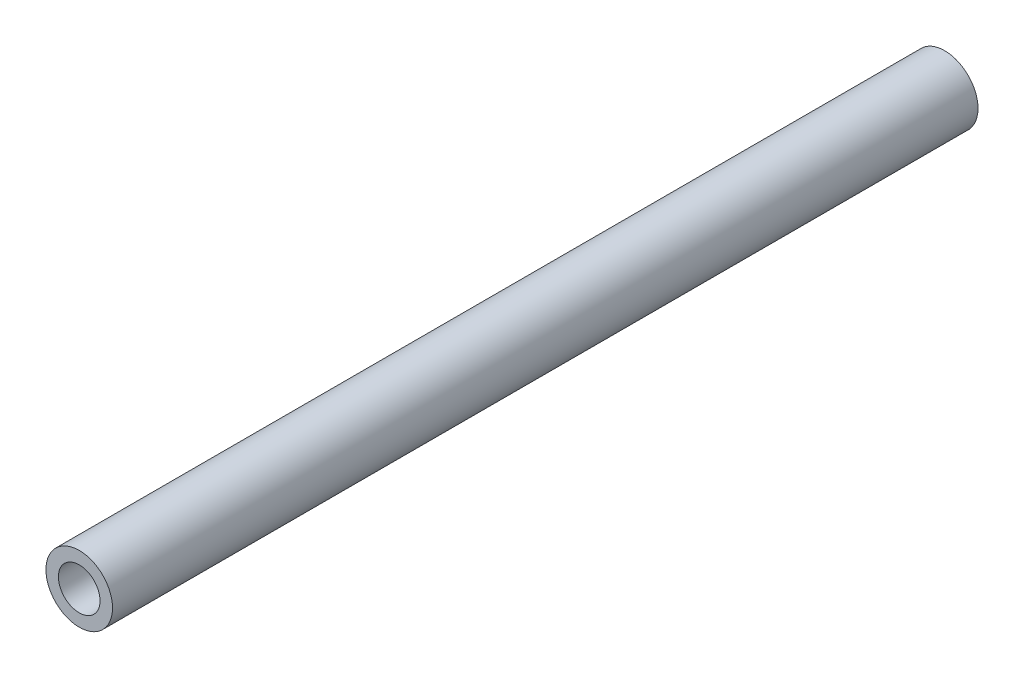
from build123d import *

# Parameters (mm, degrees)
SKETCH1_R           = 4
SKETCH1_R_2         = 2.5
BOSS_EXTRUDE1_DEPTH = 104


with BuildPart() as part:
    # Sketch1 → Boss-Extrude1 (new body)
    with BuildSketch(Plane.XY):
        Circle(SKETCH1_R)
        Circle(SKETCH1_R_2, mode=Mode.SUBTRACT)
    extrude(amount=BOSS_EXTRUDE1_DEPTH)


solid = part.part
